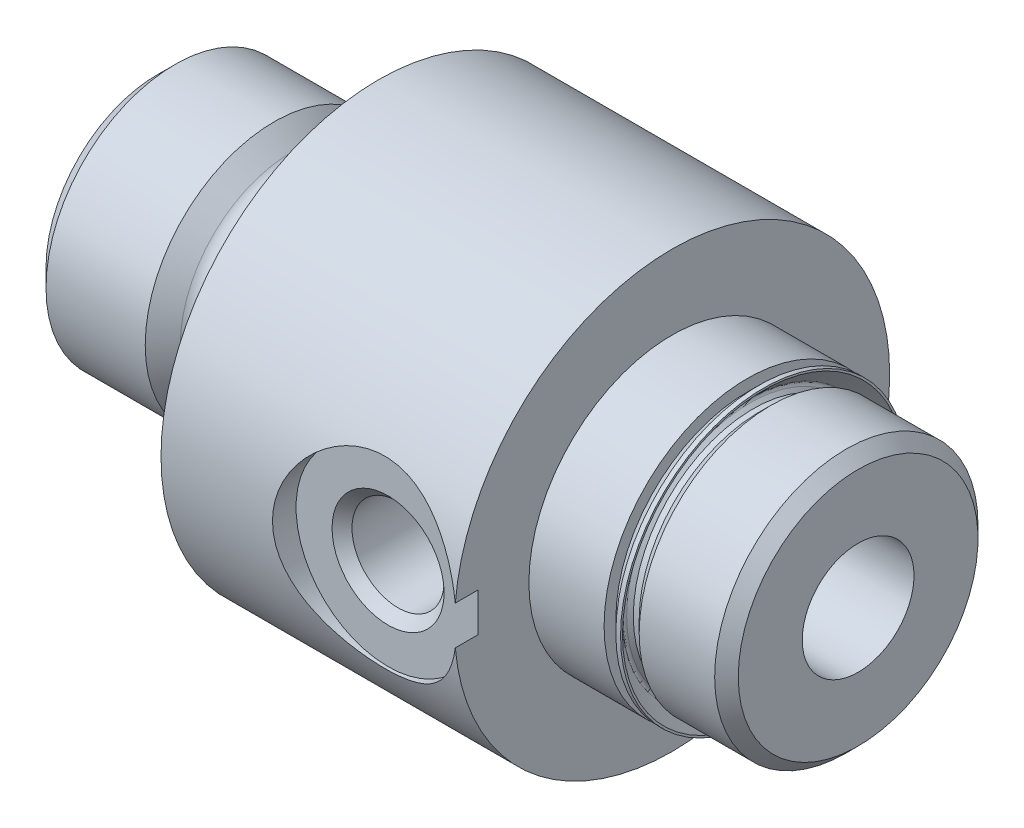
from build123d import *

# Parameters (mm, degrees)
HOLE1_D           = 4.8133
HOLE1_CSINK_D     = 5.8293
HOLE1_CSINK_ANGLE = 90
SKETCH6_W         = 3.2385
SKETCH6_H         = 3.81


with BuildPart() as part:
    # Sketch1 → Revolve1 (revolve)
    with BuildSketch(Plane.XY):
        with BuildLine():
            Line((0, 0), (0, 4.8006))
            Line((0, 4.8006), (0.75565, 5.55625))
            Line((0.75565, 5.55625), (5.028593864, 5.55625))
            Line((5.028593864, 5.55625), (5.786403291, 4.804192648))
            ThreePointArc((5.786403291, 4.804192648), (6.045223575, 4.6323221), (6.35, 4.572))
            Line((6.35, 4.572), (7.5184, 4.572))
            ThreePointArc((7.5184, 4.572), (8.084156136, 4.806343864), (8.3185, 5.3721))
            Line((8.3185, 5.3721), (8.3185, 5.5245))
            Line((8.3185, 5.5245), (9.525, 5.5245))
            Line((9.525, 5.5245), (9.525, 0))
            Line((9.525, 0), (0, 0))
        make_face()
    revolve(axis=Axis((9.525, 0, 0), (-1, 0, 0)))

    # Sketch2 → Revolve2 (revolve)
    with BuildSketch(Plane.XY):
        Polygon((9.525, 0), (9.525, 9.3726), (25.4, 9.3726), (25.4, 5.16255), (25.908, 5.16255), (26.416, 5.67055), (29.6672, 5.67055), (30.1752, 5.16255), (30.1752, 0), align=None)
    revolve(axis=Axis((30.1752, 0, 0), (-1, 0, 0)))

    # Hole1 (through all)
    with Locations(Plane.ZY):
        with Locations((0, 0)):
            CounterSinkHole(HOLE1_D / 2, HOLE1_CSINK_D / 2, counter_sink_angle=HOLE1_CSINK_ANGLE)

    # Sketch5 → Cut-Revolve1 (revolve, cut)
    with BuildSketch(Plane(origin=(0, 0, 0), x_dir=(1, 0, 0), z_dir=(0, 1, 0))):
        Polygon((18.288, 1.016), (20.27174, 1.016), (20.27174, -7.92734), (20.701, -8.3566), (22.2504, -8.3566), (22.2504, -9.3726), (18.288, -9.3726), align=None)
    revolve(axis=Axis((18.288, 0, 9.3726), (0, 0, -1)), mode=Mode.SUBTRACT)

    # Sketch6 → Cut-Revolve2 (revolve, cut)
    with BuildSketch(Plane.XY):
        with Locations((23.78075, 8.07085)):
            Rectangle(SKETCH6_W, SKETCH6_H)
    revolve(axis=Axis((25.4, 0, 0), (-1, 0, 0)), mode=Mode.SUBTRACT)

    # Sketch7 → Revolve3 (revolve)
    with BuildSketch(Plane.XY):
        with BuildLine():
            Line((25.4, 4.90855), (25.908, 4.90855))
            Line((25.908, 4.90855), (25.908, 5.16255))
            Line((25.908, 5.16255), (25.654, 5.16255))
            Line((25.654, 5.16255), (25.511592316, 5.304957684))
            ThreePointArc((25.511592316, 5.304957684), (25.474394878, 5.394760245), (25.511592316, 5.484562806))
            Line((25.511592316, 5.484562806), (26.108711314, 6.081681804))
            Line((26.108711314, 6.081681804), (26.108711314, 6.16585))
            Line((26.108711314, 6.16585), (25.905511314, 6.16585))
            Line((25.905511314, 6.16585), (25.4, 5.660338686))
            Line((25.4, 5.660338686), (25.4, 4.90855))
        make_face()
    revolve(axis=Axis((25.908, 0, 0), (-1, 0, 0)))


solid = part.part
